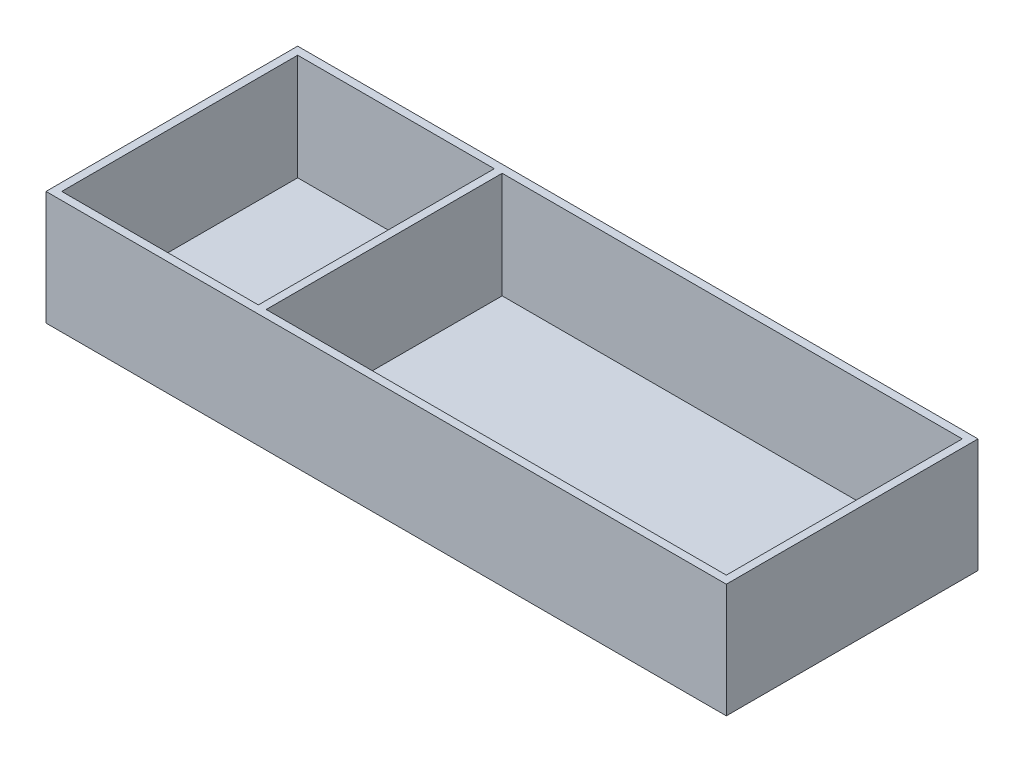
from build123d import *

# Parameters (mm, degrees)
SKETCH1_W           = 173
SKETCH1_H           = 64
BOSS_EXTRUDE1_DEPTH = 29
SHELL1_T            = -2
SKETCH3_W           = 2
SKETCH3_H           = 60
BOSS_EXTRUDE2_DEPTH = 27


with BuildPart() as part:
    # Sketch1 → Boss-Extrude1 (new body)
    with BuildSketch(Plane(origin=(0, 0, 0), x_dir=(1, 0, 0), z_dir=(0, 1, 0))):
        Rectangle(SKETCH1_W, SKETCH1_H)
    extrude(amount=BOSS_EXTRUDE1_DEPTH)

    # Shell1
    shell1_openings = [part.faces().sort_by_distance(p)[0] for p in [
        (0, 29, 0),
    ]]
    offset(amount=SHELL1_T, openings=shell1_openings, kind=Kind.INTERSECTION)

    # Sketch3 → Boss-Extrude2 (add)
    with BuildSketch(Plane(origin=(0, 2, 0), x_dir=(1, 0, 0), z_dir=(0, 1, 0))):
        with Locations((-33.5, 0)):
            Rectangle(SKETCH3_W, SKETCH3_H)
    extrude(amount=BOSS_EXTRUDE2_DEPTH)


solid = part.part
